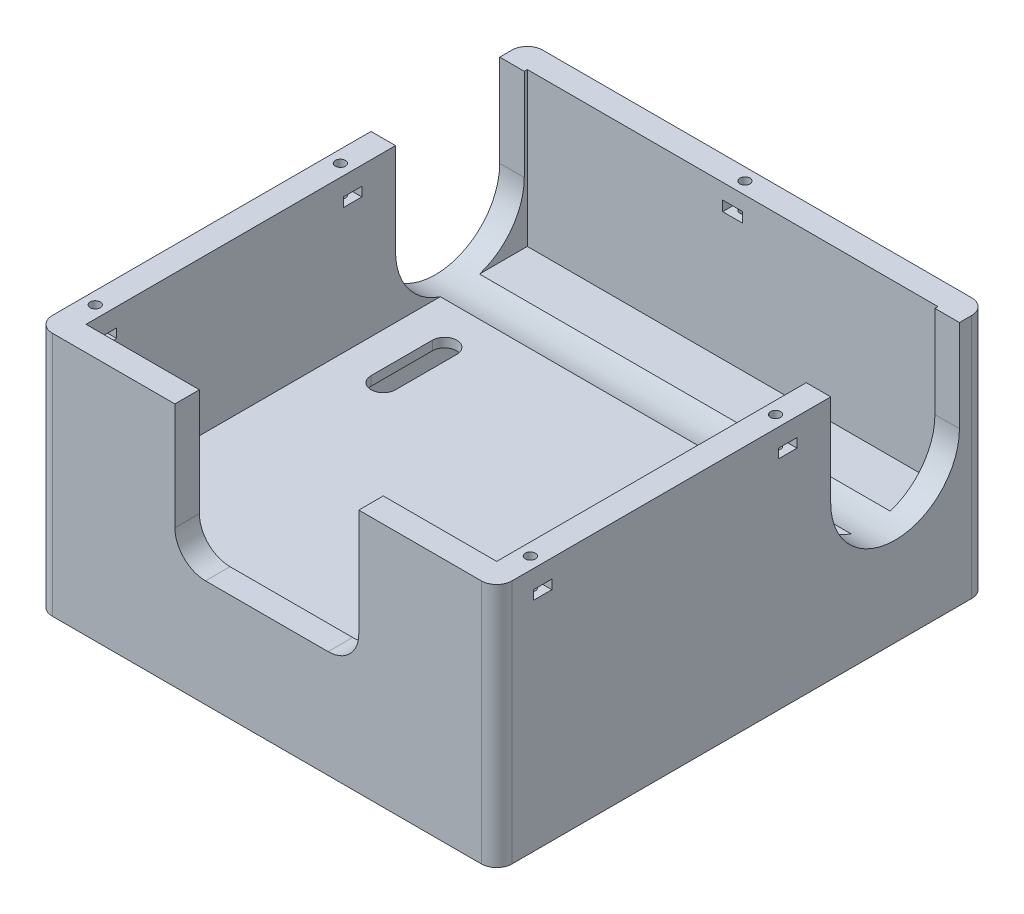
from build123d import *

# Parameters (mm, degrees)
SKETCH_1_W           = 150
SKETCH_1_H           = 160
EXTRUDE_1_DEPTH      = 80
CUT_EXTRUDE_1_DEPTH  = 151
FILLET_1_R           = 5
SKETCH_3_W           = 134
SKETCH_3_H           = 152
CUT_EXTRUDE_2_DEPTH  = 27
SKETCH_4_W           = 134
SKETCH_4_H           = 144
CUT_EXTRUDE_3_DEPTH  = 50
SKETCH_5_W           = 60
SKETCH_5_H           = 45
CUT_EXTRUDE_4_DEPTH  = 50
FILLET_2_R           = 2
SKETCH_7_R           = 1.65
CUT_EXTRUDE_6_DEPTH  = 15
SKETCH_9_W           = 6
SKETCH_9_H           = 3
CUT_EXTRUDE_7_DEPTH  = 151
SKETCH_11_R          = 1.65
CUT_EXTRUDE_8_DEPTH  = 15
SKETCH_12_W          = 6.5
SKETCH_12_H          = 3.3
CUT_EXTRUDE_9_DEPTH  = 15
FILLET_3_R           = 10
CUT_EXTRUDE_10_DEPTH = 54


with BuildPart() as part:
    # 草图1 → 凸台-拉伸1 (new body)
    with BuildSketch(Plane(origin=(0, 0, 0), x_dir=(1, 0, 0), z_dir=(0, 1, 0))):
        Rectangle(SKETCH_1_W, SKETCH_1_H)
    extrude(amount=EXTRUDE_1_DEPTH)

    # 草图2 → 切除-拉伸1 (cut, through all)
    with BuildSketch(Plane.ZY.offset(75)):
        with BuildLine():
            Line((-29, 50), (-29, 80))
            Line((-29, 80), (-71, 80))
            Line((-71, 80), (-71, 50))
            ThreePointArc((-71, 50), (-50, 29), (-29, 50))
        make_face()
    extrude(amount=-CUT_EXTRUDE_1_DEPTH, mode=Mode.SUBTRACT)

    # 圆角1
    fillet_1_edges = [part.edges().sort_by_distance(p)[0] for p in [
        (75, 40, 80),
        (-75, 40, 80),
        (-75, 40, -80),
        (75, 40, -80),
    ]]
    fillet(fillet_1_edges, radius=FILLET_1_R)

    # 草图3 → 切除-拉伸2 (cut)
    with BuildSketch(Plane.XZ):
        Rectangle(SKETCH_3_W, SKETCH_3_H)
    extrude(amount=-CUT_EXTRUDE_2_DEPTH, mode=Mode.SUBTRACT)

    # 草图4 → 切除-拉伸3 (cut)
    with BuildSketch(Plane(origin=(0, 80, 0), x_dir=(1, 0, 0), z_dir=(0, 1, 0))):
        Rectangle(SKETCH_4_W, SKETCH_4_H)
    extrude(amount=-CUT_EXTRUDE_3_DEPTH, mode=Mode.SUBTRACT)

    # 草图5 → 切除-拉伸4 (cut)
    with BuildSketch(Plane.XY.offset(80)):
        with Locations((0, 57.5)):
            Rectangle(SKETCH_5_W, SKETCH_5_H)
    extrude(amount=-CUT_EXTRUDE_4_DEPTH, mode=Mode.SUBTRACT)

    # 圆角2
    fillet_2_edges = [part.edges().sort_by_distance(p)[0] for p in [
        (-67, 13.5, -76),
        (-67, 13.5, 76),
        (67, 13.5, 76),
        (67, 13.5, -76),
    ]]
    fillet(fillet_2_edges, radius=FILLET_2_R)

    # 草图7 → 切除-拉伸6 (cut)
    with BuildSketch(Plane(origin=(0, 80, 0), x_dir=(1, 0, 0), z_dir=(0, 1, 0))):
        with Locations((-71, -65)):
            Circle(SKETCH_7_R)
        with Locations((-71, 15)):
            Circle(SKETCH_7_R)
        with Locations((71, -65)):
            Circle(SKETCH_7_R)
        with Locations((71, 15)):
            Circle(SKETCH_7_R)
    extrude(amount=-CUT_EXTRUDE_6_DEPTH, mode=Mode.SUBTRACT)

    # 草图9 → 切除-拉伸7 (cut, through all)
    with BuildSketch(Plane.ZY.offset(75)):
        with Locations((65, 72.5)):
            Rectangle(SKETCH_9_W, SKETCH_9_H)
        with Locations((-15, 72.5)):
            Rectangle(SKETCH_9_W, SKETCH_9_H)
    extrude(amount=-CUT_EXTRUDE_7_DEPTH, mode=Mode.SUBTRACT)

    # 草图11 → 切除-拉伸8 (cut)
    with BuildSketch(Plane(origin=(0, 80, 0), x_dir=(1, 0, 0), z_dir=(0, 1, 0))):
        with Locations((0, 76)):
            Circle(SKETCH_11_R)
    extrude(amount=-CUT_EXTRUDE_8_DEPTH, mode=Mode.SUBTRACT)

    # 草图12 → 切除-拉伸9 (cut)
    with BuildSketch(Plane(origin=(0, 0, -80), x_dir=(-1, 0, 0), z_dir=(0, 0, -1))):
        with Locations((0, 73.35)):
            Rectangle(SKETCH_12_W, SKETCH_12_H)
    extrude(amount=-CUT_EXTRUDE_9_DEPTH, mode=Mode.SUBTRACT)

    # 圆角3
    fillet_3_edges = [part.edges().sort_by_distance(p)[0] for p in [
        (-30, 35, 76),
        (30, 35, 76),
    ]]
    fillet(fillet_3_edges, radius=FILLET_3_R)

    # 草图13 → 切除-拉伸10 (cut, through all)
    with BuildSketch(Plane.XZ.offset(-27)):
        with BuildLine():
            Line((56, -10), (56, -30))
            ThreePointArc((56, -30), (52, -34), (48, -30))
            Line((48, -30), (48, -10))
            ThreePointArc((48, -10), (52, -6), (56, -10))
        make_face()
        with BuildLine():
            Line((-56, -10), (-56, -30))
            ThreePointArc((-56, -30), (-52, -34), (-48, -30))
            Line((-48, -30), (-48, -10))
            ThreePointArc((-48, -10), (-52, -6), (-56, -10))
        make_face()
    extrude(amount=-CUT_EXTRUDE_10_DEPTH, mode=Mode.SUBTRACT)


solid = part.part
